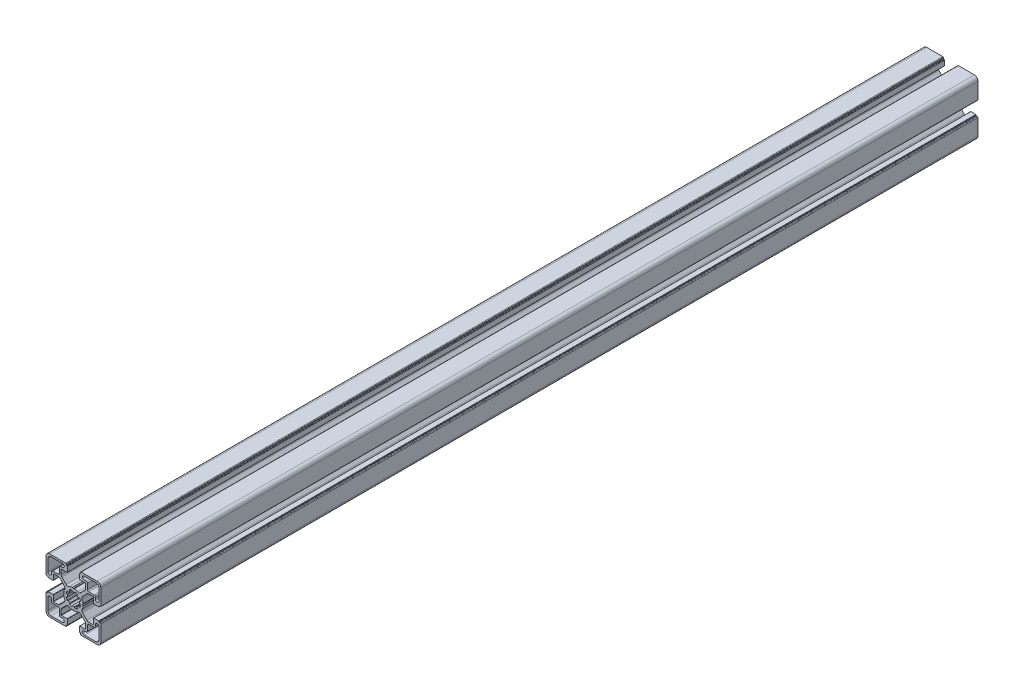
from build123d import *

# Parameters (mm, degrees)
BOSS_EXTRU_1_DEPTH = 720


with BuildPart() as part:
    # Esquisse2 → Boss.-Extru.1 (new body)
    with BuildSketch(Plane.XY):
        with BuildLine():
            Line((-192.464705439, -351.135013575), (-192.030789329, -350.389251613))
            ThreePointArc((-192.030789329, -350.389251613), (-192.008099493, -350.33058749), (-192.004751867, -350.267777448))
            ThreePointArc((-192.004751867, -350.267777448), (-192.285035172, -348.883447185), (-192.804402464, -347.569983587))
            ThreePointArc((-192.804402464, -347.569983587), (-192.985908697, -346.38788866), (-192.44128198, -345.323147062))
            Line((-192.44128198, -345.323147062), (-188.874986025, -341.756855105))
            ThreePointArc((-188.874986025, -341.756855105), (-188.244141301, -341.335338521), (-187.500009401, -341.187321592))
            Line((-187.500009401, -341.187321592), (-183.687863463, -341.187321592))
            ThreePointArc((-183.687863463, -341.187321592), (-183.546441859, -341.245900338), (-183.487863113, -341.387321941))
            Line((-183.487863113, -341.387321941), (-183.487863113, -345.981828905))
            ThreePointArc((-183.487863113, -345.981828905), (-183.429284366, -346.12325051), (-183.287862762, -346.181829256))
            Line((-183.287862762, -346.181829256), (-179.285166009, -346.181829256))
            ThreePointArc((-179.285166009, -346.181829256), (-179.073034487, -346.093961503), (-178.985166733, -345.88182998))
            Line((-178.985166733, -345.88182998), (-178.985166733, -345.681839032))
            ThreePointArc((-178.985166733, -345.681839032), (-178.897298833, -345.469707156), (-178.685166958, -345.381839256))
            Line((-178.685166958, -345.381839256), (-178.0047864, -345.381839256))
            ThreePointArc((-178.0047864, -345.381839256), (-177.651233276, -345.235392756), (-177.504786776, -344.881839631))
            Line((-177.504786776, -344.881839631), (-177.504786776, -331.681827015))
            ThreePointArc((-177.504786776, -331.681827015), (-178.383465776, -329.560508257), (-180.504784534, -328.681829257))
            Line((-180.504784534, -328.681829257), (-193.629056903, -328.681829257))
            ThreePointArc((-193.629056903, -328.681829257), (-193.982610029, -328.828275756), (-194.129056529, -329.181828882))
            Line((-194.129056529, -329.181828882), (-194.129056529, -329.881829981))
            ThreePointArc((-194.129056529, -329.881829981), (-194.216924283, -330.093961503), (-194.429055805, -330.181829256))
            Line((-194.429055805, -330.181829256), (-194.70476714, -330.181829256))
            ThreePointArc((-194.70476714, -330.181829256), (-194.916898308, -330.269696863), (-195.004765915, -330.481828031))
            Line((-195.004765915, -330.481828031), (-195.004765915, -334.515030698))
            ThreePointArc((-195.004765915, -334.515030698), (-194.946187022, -334.656452656), (-194.804765065, -334.715031549))
            Line((-194.804765065, -334.715031549), (-190.099380697, -334.715031549))
            ThreePointArc((-190.099380697, -334.715031549), (-189.957959093, -334.773610295), (-189.899380347, -334.9150319))
            Line((-189.899380347, -334.9150319), (-189.899380347, -338.710260175))
            ThreePointArc((-189.899380347, -338.710260175), (-190.051621327, -339.47562727), (-190.48516696, -340.124474162))
            Line((-190.48516696, -340.124474162), (-194.059867926, -343.699175128))
            ThreePointArc((-194.059867926, -343.699175128), (-195.150164081, -344.214009408), (-196.338266679, -344.008553194))
            ThreePointArc((-196.338266679, -344.008553194), (-197.695629231, -343.467994797), (-199.128369878, -343.181829256))
            ThreePointArc((-199.128369878, -343.181829256), (-199.191201005, -343.184754557), (-199.250016338, -343.207049503))
            Line((-199.250016338, -343.207049503), (-199.892137456, -343.574906197))
            ThreePointArc((-199.892137456, -343.574906197), (-199.941802013, -343.622754392), (-200.004765916, -343.650889155))
            ThreePointArc((-200.004765916, -343.650889155), (-200.067729818, -343.622754392), (-200.117394375, -343.574906197))
            Line((-200.117394375, -343.574906197), (-200.759515492, -343.207049503))
            ThreePointArc((-200.759515492, -343.207049503), (-200.818330825, -343.184754557), (-200.881161953, -343.181829255))
            ThreePointArc((-200.881161953, -343.181829255), (-202.3139026, -343.467994797), (-203.671265152, -344.008553193))
            ThreePointArc((-203.671265152, -344.008553193), (-204.85936775, -344.214009407), (-205.949663904, -343.699175128))
            Line((-205.949663904, -343.699175128), (-209.52436487, -340.124474162))
            ThreePointArc((-209.52436487, -340.124474162), (-209.957910503, -339.475627269), (-210.110151485, -338.710260174))
            Line((-210.110151485, -338.710260174), (-210.110151485, -334.915031899))
            ThreePointArc((-210.110151485, -334.915031899), (-210.051572738, -334.773610295), (-209.910151134, -334.715031548))
            Line((-209.910151134, -334.715031548), (-205.204766766, -334.715031548))
            ThreePointArc((-205.204766766, -334.715031548), (-205.063344808, -334.656452656), (-205.004765915, -334.515030698))
            Line((-205.004765915, -334.515030698), (-205.004765915, -330.481828032))
            ThreePointArc((-205.004765915, -330.481828032), (-205.092633523, -330.269696863), (-205.304764692, -330.181829256))
            Line((-205.304764692, -330.181829256), (-205.580476025, -330.181829256))
            ThreePointArc((-205.580476025, -330.181829256), (-205.792607548, -330.093961502), (-205.880475302, -329.88182998))
            Line((-205.880475302, -329.88182998), (-205.880475302, -329.181828882))
            ThreePointArc((-205.880475302, -329.181828882), (-206.026921801, -328.828275756), (-206.380474927, -328.681829256))
            Line((-206.380474927, -328.681829256), (-219.504747296, -328.681829256))
            ThreePointArc((-219.504747296, -328.681829256), (-221.626066055, -329.560508256), (-222.504745055, -331.681827014))
            Line((-222.504745055, -331.681827014), (-222.504745055, -344.88183963))
            ThreePointArc((-222.504745055, -344.88183963), (-222.358298555, -345.235392756), (-222.00474543, -345.381839256))
            Line((-222.00474543, -345.381839256), (-221.324364871, -345.381839256))
            ThreePointArc((-221.324364871, -345.381839256), (-221.112232996, -345.469707157), (-221.024365096, -345.681839032))
            Line((-221.024365096, -345.681839032), (-221.024365096, -345.88182998))
            ThreePointArc((-221.024365096, -345.88182998), (-220.936497342, -346.093961503), (-220.724365819, -346.181829256))
            Line((-220.724365819, -346.181829256), (-216.721669067, -346.181829256))
            ThreePointArc((-216.721669067, -346.181829256), (-216.580247463, -346.12325051), (-216.521668717, -345.981828906))
            Line((-216.521668717, -345.981828906), (-216.521668717, -341.387321942))
            ThreePointArc((-216.521668717, -341.387321942), (-216.46308997, -341.245900338), (-216.321668366, -341.187321592))
            Line((-216.321668366, -341.187321592), (-212.509522428, -341.187321592))
            ThreePointArc((-212.509522428, -341.187321592), (-211.765390527, -341.335338522), (-211.134545803, -341.756855106))
            Line((-211.134545803, -341.756855106), (-207.568249848, -345.323147062))
            ThreePointArc((-207.568249848, -345.323147062), (-207.023623131, -346.38788866), (-207.205129364, -347.569983588))
            ThreePointArc((-207.205129364, -347.569983588), (-207.724496656, -348.883447186), (-208.004779961, -350.267777448))
            ThreePointArc((-208.004779961, -350.267777448), (-208.001432335, -350.33058749), (-207.978742499, -350.389251614))
            Line((-207.978742499, -350.389251614), (-207.54482639, -351.135013575))
            ThreePointArc((-207.54482639, -351.135013575), (-207.5390619, -351.158167493), (-207.536095855, -351.181843132))
            ThreePointArc((-207.536095855, -351.181843132), (-207.5390619, -351.20551877), (-207.54482639, -351.228672687))
            Line((-207.54482639, -351.228672687), (-207.978742499, -351.974434649))
            ThreePointArc((-207.978742499, -351.974434649), (-208.001432335, -352.033098773), (-208.004779962, -352.095908815))
            ThreePointArc((-208.004779962, -352.095908815), (-207.724496656, -353.480239077), (-207.205129364, -354.793702675))
            ThreePointArc((-207.205129364, -354.793702675), (-207.023623132, -355.975797603), (-207.568249848, -357.040539202))
            Line((-207.568249848, -357.040539202), (-211.134545804, -360.606831158))
            ThreePointArc((-211.134545804, -360.606831158), (-211.765390528, -361.028347742), (-212.509522429, -361.176364671))
            Line((-212.509522429, -361.176364671), (-216.321668366, -361.176364671))
            ThreePointArc((-216.321668366, -361.176364671), (-216.463089971, -361.117785925), (-216.521668717, -360.97636432))
            Line((-216.521668717, -360.97636432), (-216.521668717, -356.381857357))
            ThreePointArc((-216.521668717, -356.381857357), (-216.580247463, -356.240435753), (-216.721669067, -356.181857007))
            Line((-216.721669067, -356.181857007), (-220.72436582, -356.181857007))
            ThreePointArc((-220.72436582, -356.181857007), (-220.936497342, -356.26972476), (-221.024365096, -356.481856283))
            Line((-221.024365096, -356.481856283), (-221.024365096, -356.68184723))
            ThreePointArc((-221.024365096, -356.68184723), (-221.112232996, -356.893979106), (-221.324364871, -356.981847005))
            Line((-221.324364871, -356.981847005), (-222.004745429, -356.981847005))
            ThreePointArc((-222.004745429, -356.981847005), (-222.358298555, -357.128293506), (-222.504745055, -357.481846632))
            Line((-222.504745055, -357.481846632), (-222.504745055, -370.681859247))
            ThreePointArc((-222.504745055, -370.681859247), (-221.626066055, -372.803178006), (-219.504747296, -373.681857006))
            Line((-219.504747296, -373.681857006), (-206.380474927, -373.681857006))
            ThreePointArc((-206.380474927, -373.681857006), (-206.026921801, -373.535410506), (-205.880475301, -373.18185738))
            Line((-205.880475301, -373.18185738), (-205.880475301, -372.481856282))
            ThreePointArc((-205.880475301, -372.481856282), (-205.792607548, -372.269724759), (-205.580476025, -372.181857005))
            Line((-205.580476025, -372.181857005), (-205.304764691, -372.181857005))
            ThreePointArc((-205.304764691, -372.181857005), (-205.092633522, -372.093989398), (-205.004765915, -371.881858229))
            Line((-205.004765915, -371.881858229), (-205.004765915, -367.848655563))
            ThreePointArc((-205.004765915, -367.848655563), (-205.063344808, -367.707233605), (-205.204766766, -367.648654712))
            Line((-205.204766766, -367.648654712), (-209.910151134, -367.648654712))
            ThreePointArc((-209.910151134, -367.648654712), (-210.051572738, -367.590075966), (-210.110151485, -367.448654362))
            Line((-210.110151485, -367.448654362), (-210.110151485, -363.653426086))
            ThreePointArc((-210.110151485, -363.653426086), (-209.957910503, -362.888058992), (-209.524364871, -362.239212099))
            Line((-209.524364871, -362.239212099), (-205.949663905, -358.664511133))
            ThreePointArc((-205.949663905, -358.664511133), (-204.85936775, -358.149676855), (-203.671265152, -358.355133067))
            ThreePointArc((-203.671265152, -358.355133067), (-202.3139026, -358.895691464), (-200.881161954, -359.181857005))
            ThreePointArc((-200.881161954, -359.181857005), (-200.818330826, -359.178931703), (-200.759515493, -359.156636757))
            Line((-200.759515493, -359.156636757), (-200.117394376, -358.788780064))
            ThreePointArc((-200.117394376, -358.788780064), (-200.067729819, -358.740931869), (-200.004765916, -358.712797106))
            ThreePointArc((-200.004765916, -358.712797106), (-199.941802013, -358.740931869), (-199.892137456, -358.788780064))
            Line((-199.892137456, -358.788780064), (-199.250016339, -359.156636758))
            ThreePointArc((-199.250016339, -359.156636758), (-199.191201006, -359.178931704), (-199.128369878, -359.181857005))
            ThreePointArc((-199.128369878, -359.181857005), (-197.695629231, -358.895691464), (-196.338266679, -358.355133068))
            ThreePointArc((-196.338266679, -358.355133068), (-195.150164082, -358.149676855), (-194.059867927, -358.664511133))
            Line((-194.059867927, -358.664511133), (-190.48516696, -362.239212099))
            ThreePointArc((-190.48516696, -362.239212099), (-190.051621328, -362.888058992), (-189.899380348, -363.653426086))
            Line((-189.899380348, -363.653426086), (-189.899380348, -367.448654362))
            ThreePointArc((-189.899380348, -367.448654362), (-189.957959094, -367.590075965), (-190.099380697, -367.648654712))
            Line((-190.099380697, -367.648654712), (-194.804765066, -367.648654712))
            ThreePointArc((-194.804765066, -367.648654712), (-194.946187023, -367.707233605), (-195.004765916, -367.848655563))
            Line((-195.004765916, -367.848655563), (-195.004765916, -371.881858229))
            ThreePointArc((-195.004765916, -371.881858229), (-194.916898309, -372.093989397), (-194.70476714, -372.181857004))
            Line((-194.70476714, -372.181857004), (-194.429055806, -372.181857004))
            ThreePointArc((-194.429055806, -372.181857004), (-194.216924283, -372.269724758), (-194.12905653, -372.48185628))
            Line((-194.12905653, -372.48185628), (-194.12905653, -373.181857379))
            ThreePointArc((-194.12905653, -373.181857379), (-193.98261003, -373.535410505), (-193.629056903, -373.681857006))
            Line((-193.629056903, -373.681857006), (-180.504784534, -373.681857006))
            ThreePointArc((-180.504784534, -373.681857006), (-178.383465775, -372.803178005), (-177.504786775, -370.681859246))
            Line((-177.504786775, -370.681859246), (-177.504786775, -357.481846631))
            ThreePointArc((-177.504786775, -357.481846631), (-177.651233275, -357.128293504), (-178.004786402, -356.981847004))
            Line((-178.004786402, -356.981847004), (-178.685166959, -356.981847004))
            ThreePointArc((-178.685166959, -356.981847004), (-178.897298836, -356.893979105), (-178.985166735, -356.681847228))
            Line((-178.985166735, -356.681847228), (-178.985166735, -356.481856281))
            ThreePointArc((-178.985166735, -356.481856281), (-179.073034488, -356.269724759), (-179.28516601, -356.181857005))
            Line((-179.28516601, -356.181857005), (-183.287862762, -356.181857005))
            ThreePointArc((-183.287862762, -356.181857005), (-183.429284367, -356.240435752), (-183.487863113, -356.381857356))
            Line((-183.487863113, -356.381857356), (-183.487863113, -360.97636432))
            ThreePointArc((-183.487863113, -360.97636432), (-183.546441859, -361.117785924), (-183.687863463, -361.176364671))
            Line((-183.687863463, -361.176364671), (-187.500009401, -361.176364671))
            ThreePointArc((-187.500009401, -361.176364671), (-188.244141302, -361.028347742), (-188.874986026, -360.606831157))
            Line((-188.874986026, -360.606831157), (-192.441281982, -357.040539201))
            ThreePointArc((-192.441281982, -357.040539201), (-192.985908698, -355.975797602), (-192.804402465, -354.793702674))
            ThreePointArc((-192.804402465, -354.793702674), (-192.285035173, -353.480239077), (-192.004751867, -352.095908814))
            ThreePointArc((-192.004751867, -352.095908814), (-192.008099493, -352.033098772), (-192.030789329, -351.974434649))
            Line((-192.030789329, -351.974434649), (-192.464705438, -351.228672687))
            ThreePointArc((-192.464705438, -351.228672687), (-192.47046993, -351.20551877), (-192.473435973, -351.181843131))
            ThreePointArc((-192.473435973, -351.181843131), (-192.47046993, -351.158167492), (-192.464705439, -351.135013575))
        make_face()
        with BuildLine():
            Line((-195.08422015, -352.069665956), (-194.515035218, -352.16805429))
            ThreePointArc((-194.515035218, -352.16805429), (-194.165013852, -352.386136153), (-194.09791825, -352.793042574))
            ThreePointArc((-194.09791825, -352.793042574), (-194.353505931, -353.535154011), (-194.702268027, -354.238303673))
            ThreePointArc((-194.702268027, -354.238303673), (-195.035805071, -354.480613812), (-195.437988264, -354.390005633))
            Line((-195.437988264, -354.390005633), (-195.915053025, -354.058342475))
            ThreePointArc((-195.915053025, -354.058342475), (-196.474632965, -354.722769754), (-197.140765494, -355.280318651))
            Line((-197.140765494, -355.280318651), (-196.813454008, -355.744441346))
            ThreePointArc((-196.813454008, -355.744441346), (-196.720150548, -356.146118205), (-196.960380945, -356.481288596))
            ThreePointArc((-196.960380945, -356.481288596), (-197.665869942, -356.825320826), (-198.409694498, -357.075915978))
            ThreePointArc((-198.409694498, -357.075915978), (-198.816910196, -357.011432294), (-199.037244235, -356.662956066))
            Line((-199.037244235, -356.662956066), (-199.137377178, -356.106032077))
            ThreePointArc((-199.137377178, -356.106032077), (-200.004765915, -356.181843131), (-200.872154653, -356.106032077))
            Line((-200.872154653, -356.106032077), (-200.972287596, -356.662956066))
            ThreePointArc((-200.972287596, -356.662956066), (-201.192621634, -357.011432294), (-201.599837332, -357.075915978))
            ThreePointArc((-201.599837332, -357.075915978), (-202.343661888, -356.825320826), (-203.049150885, -356.481288596))
            ThreePointArc((-203.049150885, -356.481288596), (-203.289381283, -356.146118205), (-203.196077822, -355.744441346))
            Line((-203.196077822, -355.744441346), (-202.868766337, -355.280318651))
            ThreePointArc((-202.868766337, -355.280318651), (-203.534898866, -354.722769754), (-204.094478805, -354.058342475))
            Line((-204.094478805, -354.058342475), (-204.571543566, -354.390005633))
            ThreePointArc((-204.571543566, -354.390005633), (-204.97372676, -354.480613812), (-205.307263804, -354.238303673))
            ThreePointArc((-205.307263804, -354.238303673), (-205.6560259, -353.535154011), (-205.91161358, -352.793042574))
            ThreePointArc((-205.91161358, -352.793042574), (-205.844517979, -352.386136153), (-205.494496613, -352.16805429))
            Line((-205.494496613, -352.16805429), (-204.925311681, -352.069665956))
            ThreePointArc((-204.925311681, -352.069665956), (-205.004765916, -351.18184313), (-204.925311681, -350.294020305))
            Line((-204.925311681, -350.294020305), (-205.494496613, -350.195631971))
            ThreePointArc((-205.494496613, -350.195631971), (-205.844517979, -349.977550108), (-205.91161358, -349.570643686))
            ThreePointArc((-205.91161358, -349.570643686), (-205.6560259, -348.82853225), (-205.307263804, -348.125382588))
            ThreePointArc((-205.307263804, -348.125382588), (-204.97372676, -347.883072448), (-204.571543566, -347.973680627))
            Line((-204.571543566, -347.973680627), (-204.094478805, -348.305343785))
            ThreePointArc((-204.094478805, -348.305343785), (-203.534898866, -347.640916506), (-202.868766337, -347.08336761))
            Line((-202.868766337, -347.08336761), (-203.196077822, -346.619244915))
            ThreePointArc((-203.196077822, -346.619244915), (-203.289381283, -346.217568056), (-203.049150885, -345.882397665))
            ThreePointArc((-203.049150885, -345.882397665), (-202.343661888, -345.538365434), (-201.599837332, -345.287770282))
            ThreePointArc((-201.599837332, -345.287770282), (-201.192621634, -345.352253967), (-200.972287596, -345.700730195))
            Line((-200.972287596, -345.700730195), (-200.872154653, -346.257654184))
            ThreePointArc((-200.872154653, -346.257654184), (-200.004765915, -346.18184313), (-199.137377178, -346.257654184))
            Line((-199.137377178, -346.257654184), (-199.037244235, -345.700730195))
            ThreePointArc((-199.037244235, -345.700730195), (-198.816910196, -345.352253967), (-198.409694498, -345.287770282))
            ThreePointArc((-198.409694498, -345.287770282), (-197.665869942, -345.538365434), (-196.960380945, -345.882397665))
            ThreePointArc((-196.960380945, -345.882397665), (-196.720150548, -346.217568056), (-196.813454008, -346.619244915))
            Line((-196.813454008, -346.619244915), (-197.140765494, -347.08336761))
            ThreePointArc((-197.140765494, -347.08336761), (-196.474632965, -347.640916506), (-195.915053025, -348.305343785))
            Line((-195.915053025, -348.305343785), (-195.437988264, -347.973680627))
            ThreePointArc((-195.437988264, -347.973680627), (-195.035805071, -347.883072448), (-194.702268027, -348.125382588))
            ThreePointArc((-194.702268027, -348.125382588), (-194.353505931, -348.82853225), (-194.09791825, -349.570643686))
            ThreePointArc((-194.09791825, -349.570643686), (-194.165013852, -349.977550108), (-194.515035218, -350.195631971))
            Line((-194.515035218, -350.195631971), (-195.08422015, -350.294020305))
            ThreePointArc((-195.08422015, -350.294020305), (-195.004765915, -351.18184313), (-195.08422015, -352.069665956))
        make_face(mode=Mode.SUBTRACT)
        with BuildLine():
            Line((-191.004786777, -330.181829255), (-181.504784909, -330.181829255))
            ThreePointArc((-181.504784909, -330.181829255), (-179.737019277, -330.914061756), (-179.004786777, -332.681827388))
            Line((-179.004786777, -332.681827388), (-179.004786777, -342.181638256))
            ThreePointArc((-179.004786777, -342.181638256), (-180.504786777, -343.681638255), (-182.004786777, -342.181638255))
            Line((-182.004786777, -342.181638255), (-182.004786777, -340.631829508))
            ThreePointArc((-182.004786777, -340.631829508), (-182.297679777, -339.924723255), (-183.00478603, -339.631830255))
            Line((-183.00478603, -339.631830255), (-187.454788523, -339.631830255))
            ThreePointArc((-187.454788523, -339.631830255), (-188.161894777, -339.338937255), (-188.454787777, -338.631831002))
            Line((-188.454787777, -338.631831002), (-188.454787777, -334.181828508))
            ThreePointArc((-188.454787777, -334.181828508), (-188.747680777, -333.474722255), (-189.45478703, -333.181829255))
            Line((-189.45478703, -333.181829255), (-191.004786777, -333.181829255))
            ThreePointArc((-191.004786777, -333.181829255), (-192.504786777, -331.681829255), (-191.004786777, -330.181829255))
        make_face(mode=Mode.SUBTRACT)
        with BuildLine():
            Line((-221.004745053, -332.681827388), (-221.004745053, -342.181638256))
            ThreePointArc((-221.004745053, -342.181638256), (-219.504745053, -343.681638255), (-218.004745054, -342.181638255))
            Line((-218.004745054, -342.181638255), (-218.004745054, -340.631829508))
            ThreePointArc((-218.004745054, -340.631829508), (-217.711852054, -339.924723255), (-217.0047458, -339.631830255))
            Line((-217.0047458, -339.631830255), (-212.554743307, -339.631830255))
            ThreePointArc((-212.554743307, -339.631830255), (-211.847637054, -339.338937255), (-211.554744054, -338.631831002))
            Line((-211.554744054, -338.631831002), (-211.554744054, -334.181828508))
            ThreePointArc((-211.554744054, -334.181828508), (-211.261851054, -333.474722255), (-210.554744801, -333.181829255))
            Line((-210.554744801, -333.181829255), (-209.004745053, -333.181829255))
            ThreePointArc((-209.004745053, -333.181829255), (-207.504745054, -331.681829255), (-209.004745053, -330.181829255))
            Line((-209.004745053, -330.181829255), (-218.504746922, -330.181829255))
            ThreePointArc((-218.504746922, -330.181829255), (-220.272512554, -330.914061756), (-221.004745053, -332.681827388))
        make_face(mode=Mode.SUBTRACT)
        with BuildLine():
            Line((-191.004786777, -372.181857005), (-181.504784909, -372.181857005))
            ThreePointArc((-181.504784909, -372.181857005), (-179.737019277, -371.449624505), (-179.004786777, -369.681858873))
            Line((-179.004786777, -369.681858873), (-179.004786777, -360.182048004))
            ThreePointArc((-179.004786777, -360.182048004), (-180.504786777, -358.682048005), (-182.004786777, -360.182048005))
            Line((-182.004786777, -360.182048005), (-182.004786777, -361.731856752))
            ThreePointArc((-182.004786777, -361.731856752), (-182.297679777, -362.438963006), (-183.00478603, -362.731856006))
            Line((-183.00478603, -362.731856006), (-187.454788523, -362.731856006))
            ThreePointArc((-187.454788523, -362.731856006), (-188.161894777, -363.024749005), (-188.454787777, -363.731855258))
            Line((-188.454787777, -363.731855258), (-188.454787777, -368.181857752))
            ThreePointArc((-188.454787777, -368.181857752), (-188.747680777, -368.888964005), (-189.45478703, -369.181857005))
            Line((-189.45478703, -369.181857005), (-191.004786777, -369.181857005))
            ThreePointArc((-191.004786777, -369.181857005), (-192.504786777, -370.681857005), (-191.004786777, -372.181857005))
        make_face(mode=Mode.SUBTRACT)
        with BuildLine():
            Line((-209.004745053, -372.181857005), (-218.504746922, -372.181857005))
            ThreePointArc((-218.504746922, -372.181857005), (-220.272512554, -371.449624505), (-221.004745053, -369.681858873))
            Line((-221.004745053, -369.681858873), (-221.004745053, -360.182048004))
            ThreePointArc((-221.004745053, -360.182048004), (-219.504745053, -358.682048005), (-218.004745054, -360.182048005))
            Line((-218.004745054, -360.182048005), (-218.004745054, -361.731856752))
            ThreePointArc((-218.004745054, -361.731856752), (-217.711852054, -362.438963006), (-217.0047458, -362.731856006))
            Line((-217.0047458, -362.731856006), (-212.554743307, -362.731856006))
            ThreePointArc((-212.554743307, -362.731856006), (-211.847637054, -363.024749005), (-211.554744054, -363.731855258))
            Line((-211.554744054, -363.731855258), (-211.554744054, -368.181857752))
            ThreePointArc((-211.554744054, -368.181857752), (-211.261851054, -368.888964005), (-210.554744801, -369.181857005))
            Line((-210.554744801, -369.181857005), (-209.004745053, -369.181857005))
            ThreePointArc((-209.004745053, -369.181857005), (-207.504745054, -370.681857005), (-209.004745053, -372.181857005))
        make_face(mode=Mode.SUBTRACT)
    extrude(amount=BOSS_EXTRU_1_DEPTH)


solid = part.part
